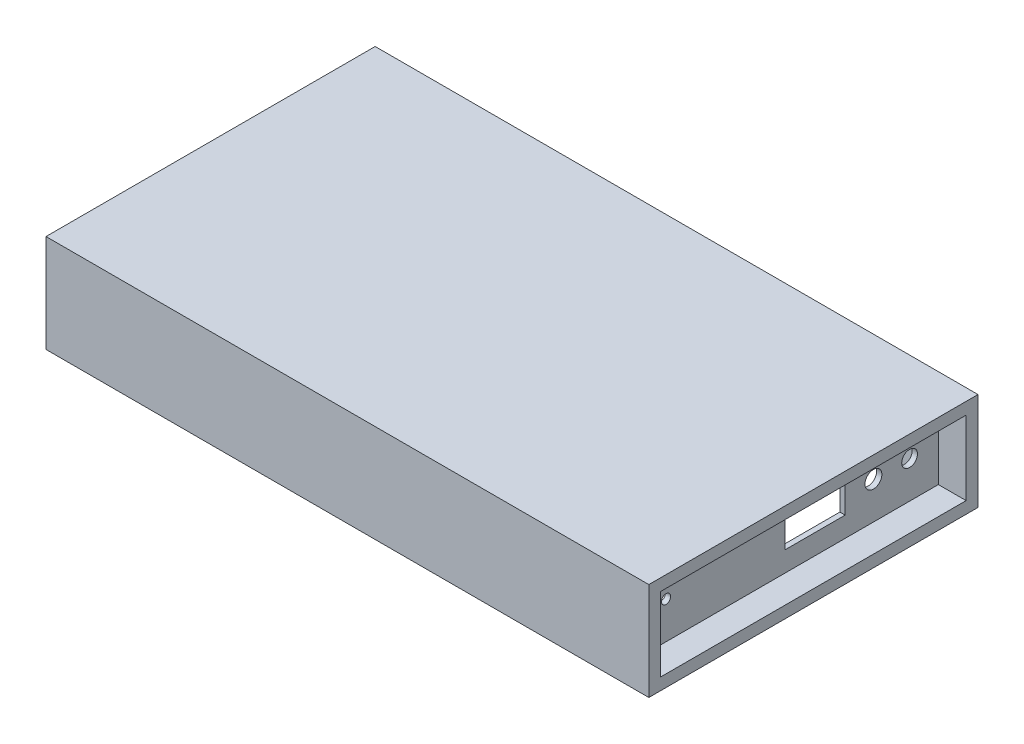
from build123d import *

# Parameters (mm, degrees)
SKETCH1_W           = 456
SKETCH1_H           = 249
SKETCH1_W_2         = 438
SKETCH1_H_2         = 231
BOSS_EXTRUDE4_DEPTH = 9
SKETCH1_5_W         = 456
SKETCH1_5_H         = 249
SKETCH1_5_W_2       = 438
SKETCH1_5_H_2       = 231
BOSS_EXTRUDE5_DEPTH = 65
SKETCH5_W           = 231
SKETCH5_H           = 56
SKETCH5_H_2         = 9
CUT_EXTRUDE1_DEPTH  = 469.544821762
SKETCH6_W           = 4
SKETCH6_H           = 231
BOSS_EXTRUDE6_DEPTH = 65
BOSS_EXTRUDE7_START = -9
SKETCH5_3_W         = 231
SKETCH5_3_H         = 9
BOSS_EXTRUDE7_DEPTH = 21
SKETCH7_R           = 3.5
SKETCH7_R_2         = 6.4
SKETCH7_R_3         = 5.96
SKETCH7_W           = 45.5
SKETCH7_H           = 25.5
CUT_EXTRUDE2_DEPTH  = 150


with BuildPart() as part:
    # Sketch1 → Boss-Extrude4 (new body)
    with BuildSketch(Plane(origin=(0, 0, 0), x_dir=(1, 0, 0), z_dir=(0, 1, 0))):
        Rectangle(SKETCH1_W, SKETCH1_H)
        Rectangle(SKETCH1_W_2, SKETCH1_H_2, mode=Mode.SUBTRACT)
        Rectangle(SKETCH1_W_2, SKETCH1_H_2)
    extrude(amount=BOSS_EXTRUDE4_DEPTH)

    # Sketch1_5 → Boss-Extrude5 (add)
    with BuildSketch(Plane(origin=(0, 0, 0), x_dir=(1, 0, 0), z_dir=(0, 1, 0))):
        Rectangle(SKETCH1_5_W, SKETCH1_5_H)
        Rectangle(SKETCH1_5_W_2, SKETCH1_5_H_2, mode=Mode.SUBTRACT)
    extrude(amount=-BOSS_EXTRUDE5_DEPTH)

    # Sketch5 → Cut-Extrude1 (cut, through all)
    with BuildSketch(Plane.ZY.offset(-219)):
        with Locations((0, -28)):
            Rectangle(SKETCH5_W, SKETCH5_H)
        with Locations((0, -60.5)):
            Rectangle(SKETCH5_W, SKETCH5_H_2)
    extrude(amount=-CUT_EXTRUDE1_DEPTH, mode=Mode.SUBTRACT)

    # Sketch6 → Boss-Extrude6 (add)
    with BuildSketch(Plane.XZ):
        with Locations((205, 0)):
            Rectangle(SKETCH6_W, SKETCH6_H)
    extrude(amount=BOSS_EXTRUDE6_DEPTH)

    # Sketch5_3 → Boss-Extrude7 (add)
    with BuildSketch(Plane.ZY.offset(-219).offset(BOSS_EXTRUDE7_START)):
        with Locations((0, -60.5)):
            Rectangle(SKETCH5_3_W, SKETCH5_3_H)
    extrude(amount=BOSS_EXTRUDE7_DEPTH)

    # Sketch7 → Cut-Extrude2 (cut)
    with BuildSketch(Plane(origin=(207, 0, 0), x_dir=(0, 0, -1), z_dir=(1, 0, 0))):
        with Locations((-90.5, -28)):
            Circle(SKETCH7_R)
        with Locations((66.4, -28)):
            Circle(SKETCH7_R_2)
        with Locations((93.76, -28)):
            Circle(SKETCH7_R_3)
        with Locations((22.25, -28)):
            Rectangle(SKETCH7_W, SKETCH7_H)
    extrude(amount=-CUT_EXTRUDE2_DEPTH, mode=Mode.SUBTRACT)


solid = part.part
